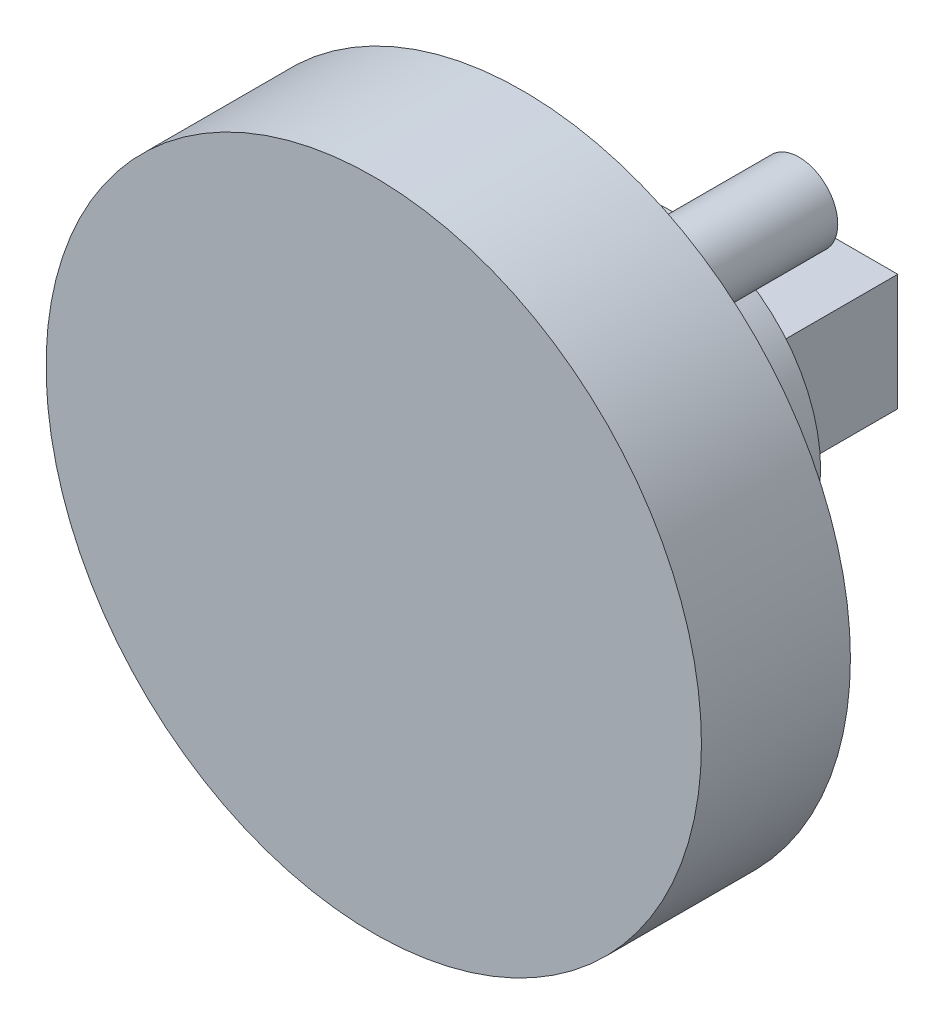
from build123d import *

# Parameters (mm, degrees)
SKETCH1_R           = 22
BOSS_EXTRUDE1_DEPTH = 10
SKETCH3_R           = 10
BOSS_EXTRUDE2_DEPTH = 10
SKETCH4_R           = 2.6
BOSS_EXTRUDE3_DEPTH = 10
SKETCH7_W           = 10.354007758
SKETCH7_H           = 7.823019208
BOSS_EXTRUDE4_DEPTH = 10


with BuildPart() as part:
    # Sketch1 → Boss-Extrude1 (new body)
    with BuildSketch(Plane.XY):
        Circle(SKETCH1_R)
    extrude(amount=BOSS_EXTRUDE1_DEPTH)

    # Sketch3 → Boss-Extrude2 (add)
    with BuildSketch(Plane(origin=(0, 0, 0), x_dir=(-1, 0, 0), z_dir=(0, 0, -1))):
        Circle(SKETCH3_R)
    extrude(amount=BOSS_EXTRUDE2_DEPTH)

    # Sketch4 → Boss-Extrude3 (add)
    with BuildSketch(Plane(origin=(0, 0, 0), x_dir=(-1, 0, 0), z_dir=(0, 0, -1))):
        with Locations((17.1, 0)):
            Circle(SKETCH4_R)
        with Locations((-8.55, -14.809034405)):
            Circle(SKETCH4_R)
        with Locations((-8.55, 14.809034405)):
            Circle(SKETCH4_R)
    extrude(amount=BOSS_EXTRUDE3_DEPTH)

    # Sketch7 → Boss-Extrude4 (add)
    with BuildSketch(Plane(origin=(0, 0, -10), x_dir=(-1, 0, 0), z_dir=(0, 0, -1))):
        Rectangle(SKETCH7_W, SKETCH7_H)
    extrude(amount=BOSS_EXTRUDE4_DEPTH)


solid = part.part
